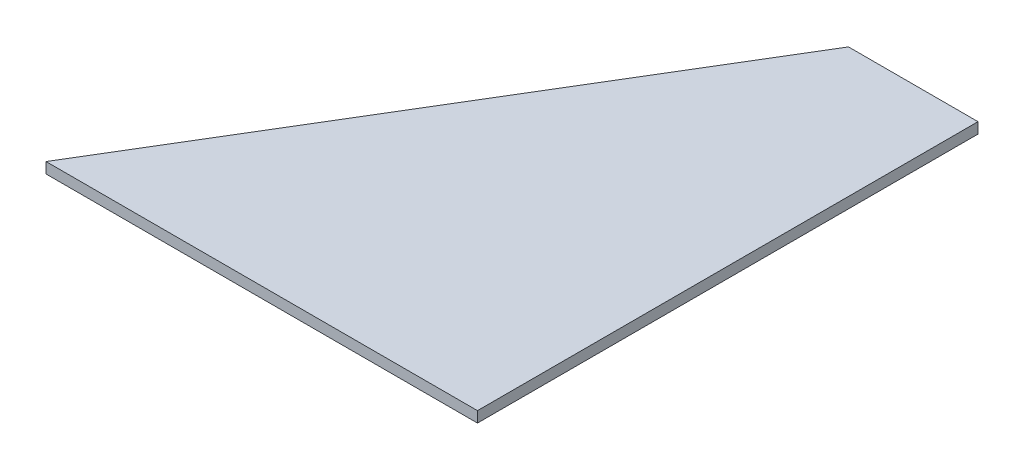
from build123d import *

# Parameters (mm, degrees)
BOSS_EXTRUDE1_DEPTH = 3.175


with BuildPart() as part:
    # Sketch1 → Boss-Extrude1 (new body)
    with BuildSketch(Plane(origin=(0, 0, 0), x_dir=(1, 0, 0), z_dir=(0, 1, 0))):
        Polygon((0, 0), (0, 147.32), (-38.1, 147.32), (-127, 0), align=None)
    extrude(amount=BOSS_EXTRUDE1_DEPTH)


solid = part.part
